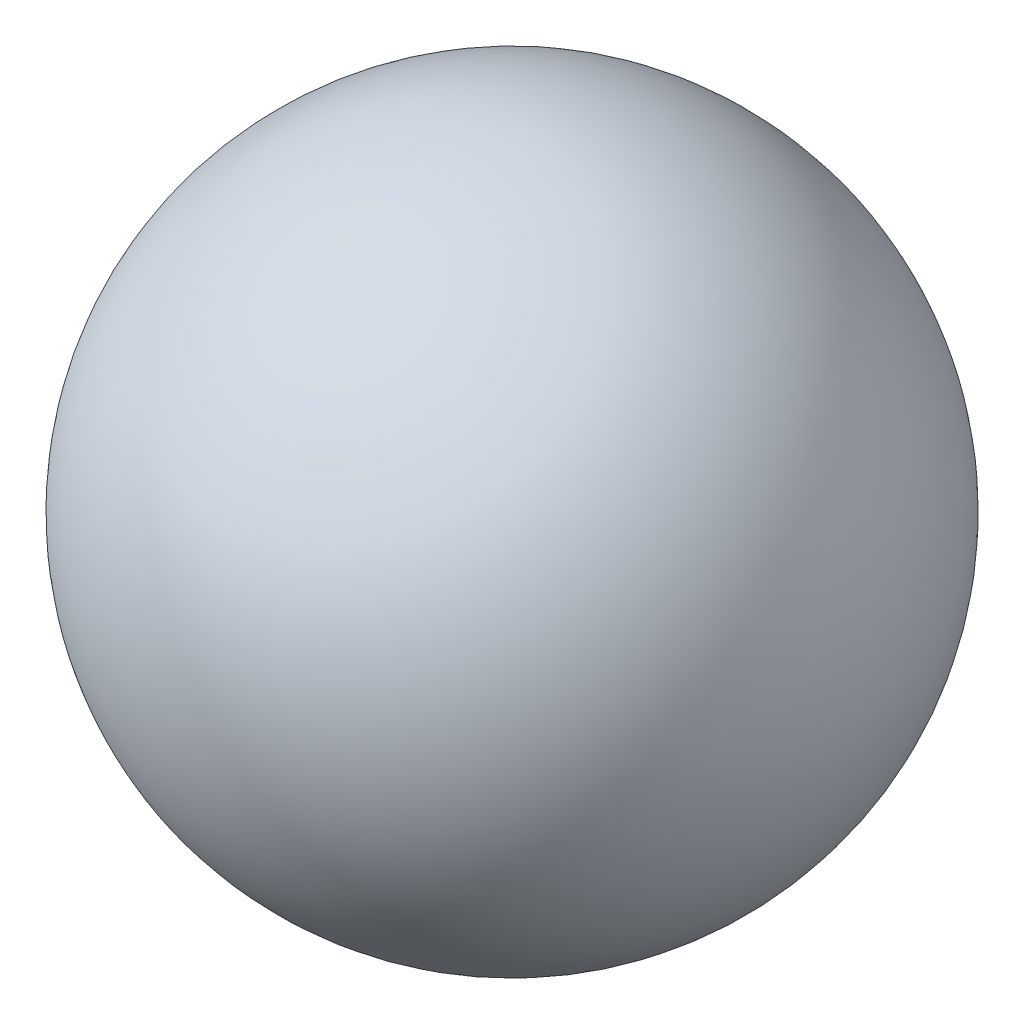
from build123d import *


with BuildPart() as part:
    # Sketch1 → Revolve1 (revolve)
    with BuildSketch(Plane(origin=(0, 0, 0), x_dir=(1, 0, 0), z_dir=(0, 1, 0))):
        with BuildLine():
            ThreePointArc((0, 44.45), (-44.45, 0), (0, -44.45))
            Line((0, -44.45), (0, -42.45))
            ThreePointArc((0, -42.45), (-42.45, 0), (0, 42.45))
            Line((0, 42.45), (0, 44.45))
        make_face()
    revolve(axis=Axis((0, 0, 44.45), (0, 0, -1)))


solid = part.part
